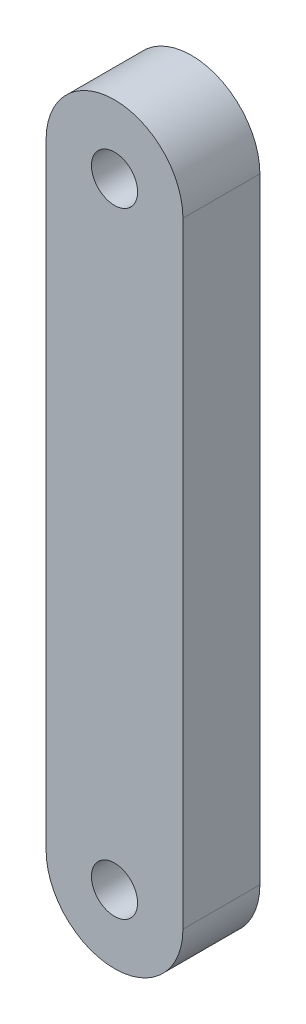
from build123d import *

# Parameters (mm, degrees)
EXTRUDE_3_DEPTH = 1


with BuildPart() as part:
    # 草图1 → 凸台-拉伸3 (new body)
    with BuildSketch(Plane.XY):
        with BuildLine():
            ThreePointArc((-0.3, 4), (0, 4.3), (0.3, 4))
            Line((0.3, 4), (0.888888889, 4))
            ThreePointArc((0.888888889, 4), (0, 4.888888889), (-0.888888889, 4))
            Line((-0.888888889, 4), (-0.3, 4))
        make_face()
        with BuildLine():
            Line((0.888888889, 4), (0.3, 4))
            ThreePointArc((0.3, 4), (0, 3.7), (-0.3, 4))
            Line((-0.3, 4), (-0.888888889, 4))
            ThreePointArc((-0.888888889, 4), (0, 3.111111111), (0.888888889, 4))
        make_face()
        with BuildLine():
            Line((0.888888889, -4), (0.888888889, 4))
            ThreePointArc((0.888888889, 4), (0, 3.111111111), (-0.888888889, 4))
            Line((-0.888888889, 4), (-0.888888889, -4))
            ThreePointArc((-0.888888889, -4), (0, -3.111111111), (0.888888889, -4))
        make_face()
        with BuildLine():
            ThreePointArc((-0.888888889, -4), (0, -4.888888889), (0.888888889, -4))
            Line((0.888888889, -4), (0.3, -4))
            ThreePointArc((0.3, -4), (0, -4.3), (-0.3, -4))
            Line((-0.3, -4), (-0.888888889, -4))
        make_face()
        with BuildLine():
            Line((0.3, -4), (0.888888889, -4))
            ThreePointArc((0.888888889, -4), (0, -3.111111111), (-0.888888889, -4))
            Line((-0.888888889, -4), (-0.3, -4))
            ThreePointArc((-0.3, -4), (0, -3.7), (0.3, -4))
        make_face()
    extrude(amount=EXTRUDE_3_DEPTH)


solid = part.part
